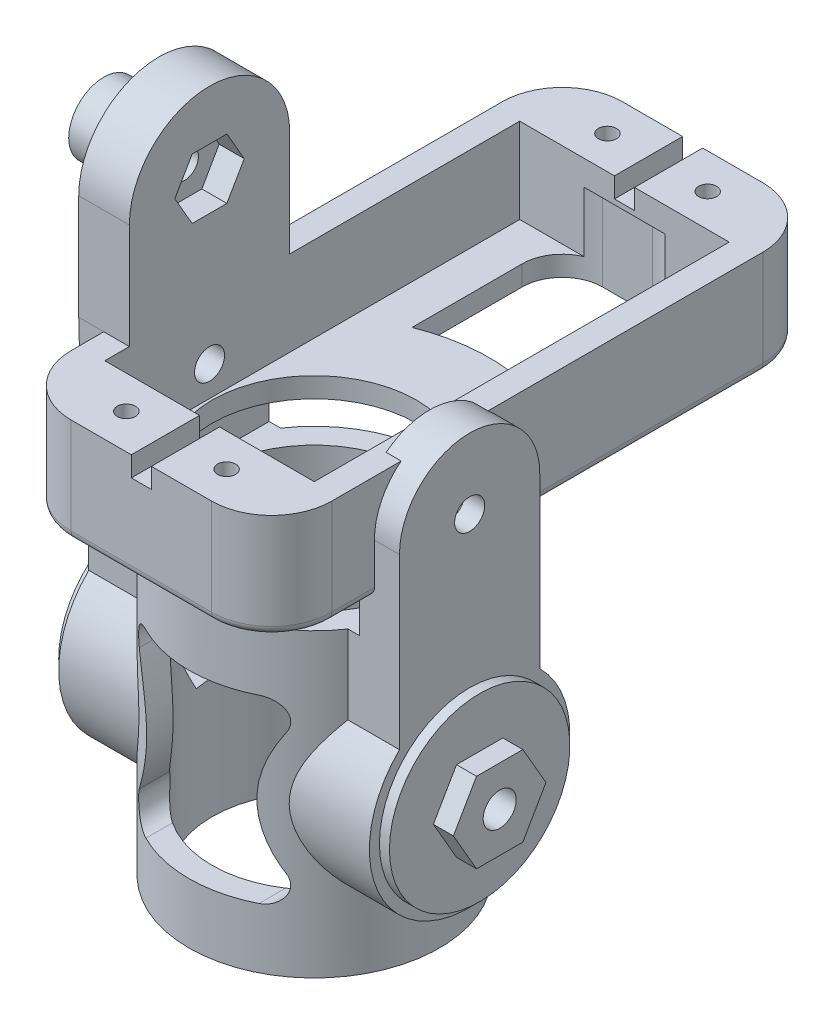
from build123d import *
from build123d.topology import SkipClean

# Parameters (mm, degrees)
CROQUIS1_R                   = 12.5
CROQUIS1_R_2                 = 10.2
SALIENTE_EXTRUIR1_DEPTH      = 15
SALIENTE_EXTRUIR1_DEPTH_BACK = 15
SALIENTE_EXTRUIR2_REACH      = 36.136
SALIENTE_EXTRUIR2_END_RADIUS = 12.5
CROQUIS3_R                   = 1.5
SALIENTE_EXTRUIR3_DEPTH      = 4
CROQUIS4_W                   = 26
CROQUIS4_H                   = 55
CROQUIS4_W_2                 = 20.9
CROQUIS4_H_2                 = 41.4
SALIENTE_EXTRUIR4_DEPTH      = 8.5
CROQUIS5_W                   = 26
CROQUIS5_H                   = 55
CROQUIS5_R                   = 10.2
SALIENTE_EXTRUIR5_DEPTH      = 2
CORTAR_EXTRUIR2_START        = -2
CROQUIS7_R                   = 2.9
CORTAR_EXTRUIR2_DEPTH        = 5
CROQUIS8_R                   = 1.85
CORTAR_EXTRUIR3_DEPTH        = 8
REDONDEO1_R                  = 6
CORTAR_EXTRUIR4_DEPTH        = 8
CORTAR_EXTRUIR5_DEPTH        = 20
CORTAR_EXTRUIR5_DEPTH_BACK   = 20
CORTAR_EXTRUIR6_START        = -2
CORTAR_EXTRUIR6_DEPTH        = 6
SALIENTE_EXTRUIR6_DEPTH      = 3
CROQUIS13_R                  = 1.65
CORTAR_EXTRUIR7_DEPTH        = 6
REDONDEO3_R                  = 0.9
CROQUIS15_R                  = 0.9
CORTAR_EXTRUIR8_DEPTH        = 9
CROQUIS16_R                  = 9
CROQUIS16_R_2                = 1.65
SALIENTE_EXTRUIR8_DEPTH      = 1
SALIENTE_EXTRUIR9_START      = -25.95
CROQUIS17_R                  = 1.5
CROQUIS17_R_2                = 1.4
SALIENTE_EXTRUIR9_DEPTH      = 5.05
CORTAR_EXTRUIR9_DEPTH        = 2.5
CROQUIS21_R                  = 3.5
CROQUIS21_R_2                = 1.4
SALIENTE_EXTRUIR10_DEPTH     = 5.5
CROQUIS22_W                  = 2
CROQUIS22_H                  = 79.078699254
CORTAR_EXTRUIR10_DEPTH       = 2


with BuildPart() as part:
    # Croquis1 → Saliente-Extruir1 (new, two sides)
    with BuildSketch(Plane(origin=(0, 0, 0), x_dir=(1, 0, 0), z_dir=(0, 1, 0))) as saliente_extruir1_sk:
        with Locations(Location((0, 0, 0), (0, 0, 270))):
            Circle(CROQUIS1_R)
        with Locations(Location((0, 0, 0), (0, 0, 270))):
            Circle(CROQUIS1_R_2, mode=Mode.SUBTRACT)
    extrude(amount=SALIENTE_EXTRUIR1_DEPTH)
    extrude(saliente_extruir1_sk.sketch, amount=-SALIENTE_EXTRUIR1_DEPTH_BACK)

    # Saliente-Extruir2: up to this cylinder (the profile starts outside it)
    saliente_extruir2_end = Plane(origin=(0, 2.494351, 0), z_dir=(0, 1, 0)) * Cylinder(SALIENTE_EXTRUIR2_END_RADIUS, 98.272, mode=Mode.PRIVATE)
    # Croquis2 → Saliente-Extruir2 (add, up to the surface)
    with BuildSketch(Plane(origin=(15.5, 0, 0), x_dir=(0, 0, -1), z_dir=(1, 0, 0)), mode=Mode.PRIVATE) as saliente_extruir2_sk1:
        with BuildLine():
            Line((-7, 7.141428429), (-7, 15))
            Line((-7, 15), (7, 15))
            Line((7, 15), (7, 7.141428429))
            ThreePointArc((7, 7.141428429), (0, -10), (-7, 7.141428429))
        make_face()
    saliente_extruir2_tool1 = extrude(saliente_extruir2_sk1.sketch, amount=-SALIENTE_EXTRUIR2_REACH, mode=Mode.PRIVATE) - saliente_extruir2_end
    saliente_extruir2 = saliente_extruir2_tool1.solids().sort_by_distance((15.5, 2.494351, 0))[0]
    add(saliente_extruir2)

    # Croquis3 → Saliente-Extruir3 (add)
    with BuildSketch(Plane(origin=(15.5, 0, 0), x_dir=(0, 0, -1), z_dir=(1, 0, 0))):
        with BuildLine():
            Line((-7, 15), (-7, 24))
            ThreePointArc((-7, 24), (0, 31), (7, 24))
            Line((7, 24), (7, 15))
            Line((7, 15), (-7, 15))
        make_face()
        with Locations((0, 24)):
            Circle(CROQUIS3_R, mode=Mode.SUBTRACT)
    saliente_extruir3 = extrude(amount=-SALIENTE_EXTRUIR3_DEPTH)

    # Croquis4 → Saliente-Extruir4 (add)
    with BuildSketch(Plane(origin=(0, 29.5, 0), x_dir=(1, 0, 0), z_dir=(0, 1, 0))):
        with Locations((0, 10.25)):
            Rectangle(CROQUIS4_W, CROQUIS4_H)
        with Locations((0, 10.25)):
            Rectangle(CROQUIS4_W_2, CROQUIS4_H_2, mode=Mode.SUBTRACT)
    extrude(amount=-SALIENTE_EXTRUIR4_DEPTH)

    # Croquis5 → Saliente-Extruir5 (add)
    with BuildSketch(Plane.XZ.offset(-21)):
        with Locations((0, -10.25)):
            Rectangle(CROQUIS5_W, CROQUIS5_H)
        with Locations(Location((0, 0, 0), (0, 0, 90))):
            Circle(CROQUIS5_R, mode=Mode.SUBTRACT)
    extrude(amount=SALIENTE_EXTRUIR5_DEPTH)

    # Simetr_a1: Saliente-Extruir2, Saliente-Extruir3 across plane
    add(saliente_extruir2.mirror(Plane(origin=(0, 0, 0), x_dir=(0, 0, 1), z_dir=(1, 0, 0))))
    add(saliente_extruir3.mirror(Plane(origin=(0, 0, 0), x_dir=(0, 0, 1), z_dir=(1, 0, 0))))

    # Croquis7 → Cortar-Extruir2 (cut)
    with BuildSketch(Plane(origin=(15.5, 0, 0), x_dir=(0, 0, -1), z_dir=(1, 0, 0)).offset(CORTAR_EXTRUIR2_START)):
        with Locations((0, 24)):
            Circle(CROQUIS7_R)
    extrude(amount=-CORTAR_EXTRUIR2_DEPTH, mode=Mode.SUBTRACT)

    # Croquis8 → Cortar-Extruir3 (cut)
    with BuildSketch(Plane.ZY.offset(15.5)):
        with Locations((0, 24)):
            Circle(CROQUIS8_R)
    extrude(amount=-CORTAR_EXTRUIR3_DEPTH, mode=Mode.SUBTRACT)

    # Redondeo1
    redondeo1_edges = [part.edges().sort_by_distance(p)[0] for p in [
        (13, 24.25, -37.75),
        (13, 24.25, 17.25),
        (-13, 24.25, 17.25),
        (-13, 24.25, -37.75),
    ]]
    fillet(redondeo1_edges, radius=REDONDEO1_R)

    # Croquis9 → Cortar-Extruir4 (cut)
    with BuildSketch(Plane.XZ.offset(-19)):
        with BuildLine():
            Line((-6.5, -16.248076809), (-6.5, -27.25))
            ThreePointArc((-6.5, -27.25), (-5.328427125, -30.078427125), (-2.5, -31.25))
            Line((-2.5, -31.25), (2.5, -31.25))
            ThreePointArc((2.5, -31.25), (5.328427125, -30.078427125), (6.5, -27.25))
            Line((6.5, -27.25), (6.5, -16.248076809))
            ThreePointArc((6.5, -16.248076809), (0, -17.5), (-6.5, -16.248076809))
        make_face()
    extrude(amount=-CORTAR_EXTRUIR4_DEPTH, mode=Mode.SUBTRACT)

    # Croquis10 → Cortar-Extruir5 (cut, two sides)
    with BuildSketch(Plane.XY) as cortar_extruir5_sk:
        with BuildLine():
            Line((5.642207049, 9), (-5.642207049, 9))
            ThreePointArc((-5.642207049, 9), (-7.322033318, 8.035949496), (-7.337095906, 6.099204085))
            add(Edge.make_bspline(
                [(-7.337095906, -6.099204085), (-7.255109422, -5.953736381), (-7.011344415, -5.505212973), (-6.483334621, -4.444786073), (-5.914238741, -2.927604755), (-5.509083096, -1.100865162), (-5.491601573, 0.975451907), (-5.890934531, 2.865636268), (-6.483688877, 4.446301578), (-6.989099561, 5.462892393), (-7.245567988, 5.936807119), (-7.337095906, 6.099204085)],
                knots=[0.073110245, 0.073110245, 0.073110245, 0.078884546, 0.091608945, 0.126254753, 0.172449164, 0.24174078, 0.334129602, 0.426518424, 0.518907246, 0.561734839, 0.584832044, 0.584832044, 0.584832044], degree=2))
            ThreePointArc((-7.337095906, -6.099204085), (-7.322033318, -8.035949496), (-5.642207049, -9))
            Line((-5.642207049, -9), (5.642207049, -9))
            ThreePointArc((5.642207049, -9), (7.322033318, -8.035949496), (7.337095906, -6.099204085))
            add(Edge.make_bspline(
                [(7.337095906, -6.099204085), (7.255109422, -5.953736381), (7.011344415, -5.505212973), (6.483334621, -4.444786073), (5.914238741, -2.927604755), (5.509083096, -1.100865162), (5.491601573, 0.975451907), (5.890934531, 2.865636268), (6.483688877, 4.446301578), (6.989099561, 5.462892393), (7.245567988, 5.936807119), (7.337095906, 6.099204085)],
                knots=[0.073110245, 0.073110245, 0.073110245, 0.078884546, 0.091608945, 0.126254753, 0.172449164, 0.24174078, 0.334129602, 0.426518424, 0.518907246, 0.561734839, 0.584832044, 0.584832044, 0.584832044], degree=2))
            ThreePointArc((7.337095906, 6.099204085), (7.322033318, 8.035949496), (5.642207049, 9))
        make_face()
    extrude(amount=CORTAR_EXTRUIR5_DEPTH, mode=Mode.SUBTRACT)
    extrude(cortar_extruir5_sk.sketch, amount=-CORTAR_EXTRUIR5_DEPTH_BACK, mode=Mode.SUBTRACT)

    # Croquis11 → Cortar-Extruir6 (cut)
    with BuildSketch(Plane.ZY.offset(15.5).offset(CORTAR_EXTRUIR6_START)):
        Polygon((-1.732050808, 3), (-3.464101615, 0), (-1.732050808, -3), (1.732050808, -3), (3.464101615, 0), (1.732050808, 3), align=None)
    cortar_extruir6 = extrude(amount=-CORTAR_EXTRUIR6_DEPTH, mode=Mode.SUBTRACT)

    # Croquis12 → Saliente-Extruir6 (add)
    with BuildSketch(Plane.ZY.offset(15.5)):
        Polygon((2.309401077, 4), (-2.309401077, 4), (-4.618802154, 0), (-2.309401077, -4), (2.309401077, -4), (4.618802154, 0), align=None)
    saliente_extruir6 = extrude(amount=SALIENTE_EXTRUIR6_DEPTH)

    # Croquis13 → Cortar-Extruir7 (cut)
    with BuildSketch(Plane.ZY.offset(18.5)):
        Circle(CROQUIS13_R)
    cortar_extruir7 = extrude(amount=-CORTAR_EXTRUIR7_DEPTH, mode=Mode.SUBTRACT)

    # Redondeo3
    redondeo3_edges = [part.edges().sort_by_distance(p)[0] for p in [
        (-13, 19, -19.375),
        (0, 19, 17.25),
        (0, 19, -37.75),
        (13, 19, -19.375),
        (-13, 19, 9.125),
        (11.242640687, 19, -35.992640687),
        (-11.242640687, 19, -35.992640687),
        (-11.242640687, 19, 15.492640687),
        (11.242640687, 19, 15.492640687),
        (13, 19, 9.125),
    ]]
    fillet(redondeo3_edges, radius=REDONDEO3_R)

    # Croquis15 → Cortar-Extruir8 (cut)
    with BuildSketch(Plane(origin=(0, 29.5, 0), x_dir=(1, 0, 0), z_dir=(0, 1, 0))):
        with Locations(Location((-5, 34.25, 0), (0, 0, 270))):
            Circle(CROQUIS15_R)
        with Locations(Location((5, 34.25, 0), (0, 0, 270))):
            Circle(CROQUIS15_R)
        with Locations(Location((-5, -13.75, 0), (0, 0, 270))):
            Circle(CROQUIS15_R)
        with Locations(Location((5, -13.75, 0), (0, 0, 270))):
            Circle(CROQUIS15_R)
    extrude(amount=-CORTAR_EXTRUIR8_DEPTH, mode=Mode.SUBTRACT)

    # Croquis16 → Saliente-Extruir8 (add)
    with BuildSketch(Plane.ZY.offset(15.5)):
        Circle(CROQUIS16_R)
        Circle(CROQUIS16_R_2, mode=Mode.SUBTRACT)
    saliente_extruir8 = extrude(amount=SALIENTE_EXTRUIR8_DEPTH)

    # Simetr_a2: Cortar-Extruir6, Saliente-Extruir6, Cortar-Extruir7, Saliente-Extruir8 across plane
    add(cortar_extruir6.mirror(Plane(origin=(0, 0, 0), x_dir=(0, 0, 1), z_dir=(1, 0, 0))), mode=Mode.SUBTRACT)
    add(saliente_extruir6.mirror(Plane(origin=(0, 0, 0), x_dir=(0, 0, 1), z_dir=(1, 0, 0))))
    add(cortar_extruir7.mirror(Plane(origin=(0, 0, 0), x_dir=(0, 0, 1), z_dir=(1, 0, 0))), mode=Mode.SUBTRACT)
    add(saliente_extruir8.mirror(Plane(origin=(0, 0, 0), x_dir=(0, 0, 1), z_dir=(1, 0, 0))))

    # Croquis17 → Saliente-Extruir9 (add)
    with BuildSketch(Plane(origin=(15.5, 0, 0), x_dir=(0, 0, -1), z_dir=(1, 0, 0)).offset(SALIENTE_EXTRUIR9_START)):
        with BuildLine():
            Line((-8, 40), (-8, 29.5))
            ThreePointArc((-8, 29.5), (-7.749325486, 24.674028595), (-7, 19.9))
            Line((-7, 19.9), (7, 19.9))
            ThreePointArc((7, 19.9), (7.749325486, 24.674028595), (8, 29.5))
            Line((8, 29.5), (8, 40))
            ThreePointArc((8, 40), (0, 48), (-8, 40))
        make_face()
        with Locations((0, 24)):
            Circle(CROQUIS17_R, mode=Mode.SUBTRACT)
        with Locations(Location((0, 40, 0), (0, 0, 180))):
            Circle(CROQUIS17_R_2, mode=Mode.SUBTRACT)
    extrude(amount=-SALIENTE_EXTRUIR9_DEPTH)

    # Croquis19 → Cortar-Extruir9 (cut)
    with BuildSketch(Plane(origin=(-10.45, 0, 0), x_dir=(0, 0, -1), z_dir=(1, 0, 0))):
        Polygon((1.732050808, 43), (-1.732050808, 43), (-3.464101615, 40), (-1.732050808, 37), (1.732050808, 37), (3.464101615, 40), align=None)
    extrude(amount=-CORTAR_EXTRUIR9_DEPTH, mode=Mode.SUBTRACT)

    # Croquis21 → Saliente-Extruir10 (add)
    with SkipClean():  # the faces are left unmerged after this step: merging them gives an invalid solid
        with BuildSketch(Plane.ZY.offset(15.5)):
            with Locations((0, 40)):
                Circle(CROQUIS21_R)
            with Locations(Location((0, 40, 0), (0, 0, 180))):
                Circle(CROQUIS21_R_2, mode=Mode.SUBTRACT)
        extrude(amount=SALIENTE_EXTRUIR10_DEPTH)

    # Croquis22 → Cortar-Extruir10 (cut)
    with SkipClean():  # the faces are left unmerged after this step: merging them gives an invalid solid
        with BuildSketch(Plane(origin=(0, 29.5, 0), x_dir=(1, 0, 0), z_dir=(0, 1, 0))):
            Rectangle(CROQUIS22_W, CROQUIS22_H)
        extrude(amount=-CORTAR_EXTRUIR10_DEPTH, mode=Mode.SUBTRACT)


solid = part.part
